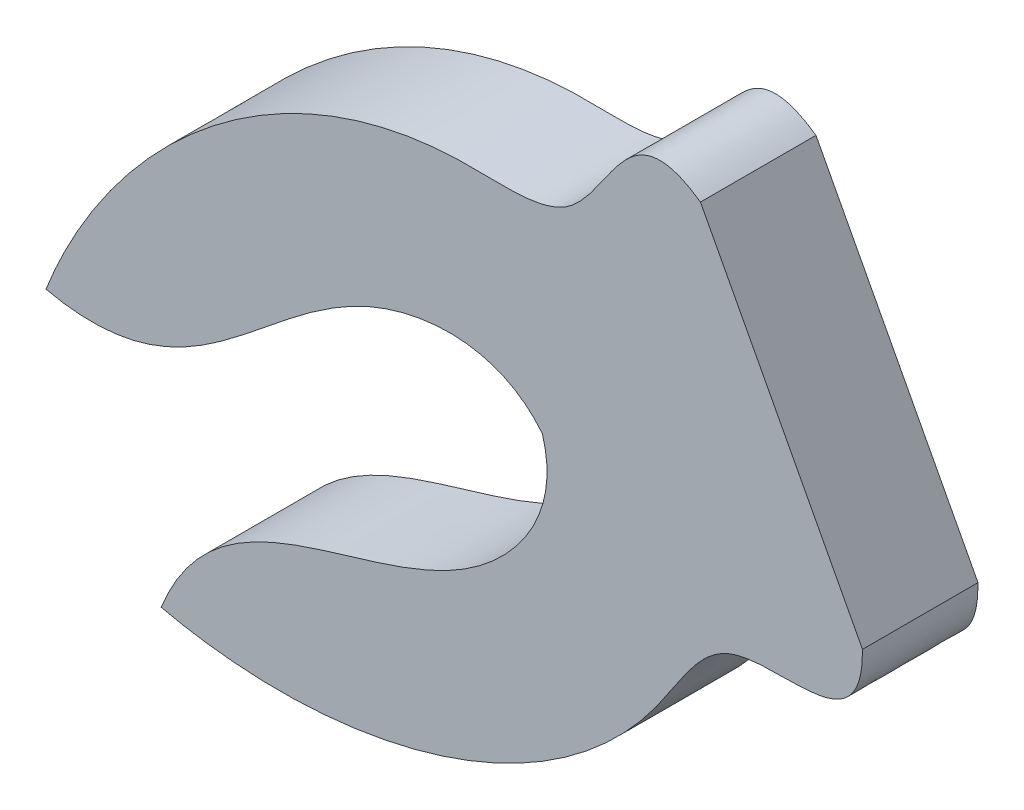
from build123d import *

# Parameters (mm, degrees)
BOSS_EXTRUDE1_DEPTH = 3.175


with BuildPart() as part:
    # Sketch1 → Boss-Extrude1 (new body)
    with BuildSketch(Plane.XY):
        with BuildLine():
            Line((184.170901213, 171.16443677), (188.623811439, 162.744388343))
            add(Edge.make_bspline(
                [(188.623811439, 162.744388343), (188.663646352, 160.236577893), (184.920317244, 162.032555721), (181.133127764, 154.570416896), (174.078388586, 153.02227532), (169.349928801, 154.108528332)],
                knots=[0, 0, 0, 0, 0.207300481, 0.334319205, 1, 1, 1, 1], degree=3))
            add(Edge.make_bspline(
                [(169.349928801, 154.108528332), (170.941079424, 158.109537527), (176.997356853, 156.990356799), (180.330722428, 161.828121575), (179.826186231, 163.479274525)],
                knots=[0, 0, 0, 0, 0.681893717, 1, 1, 1, 1], degree=3))
            add(Edge.make_bspline(
                [(166.183974101, 160.095060855), (170.386575048, 159.158054893), (172.87057403, 164.793727954), (178.74545881, 164.825710963), (179.826186231, 163.479274525)],
                knots=[0, 0, 0, 0, 0.681893717, 1, 1, 1, 1], degree=3))
            add(Edge.make_bspline(
                [(184.170901213, 171.16443677), (182.120543743, 172.608990098), (181.497879866, 168.504073672), (173.198417299, 169.574233049), (167.947769761, 164.614718189), (166.183974101, 160.095060855)],
                knots=[0, 0, 0, 0, 0.207300481, 0.334319205, 1, 1, 1, 1], degree=3))
        make_face()
    extrude(amount=BOSS_EXTRUDE1_DEPTH)


solid = part.part
